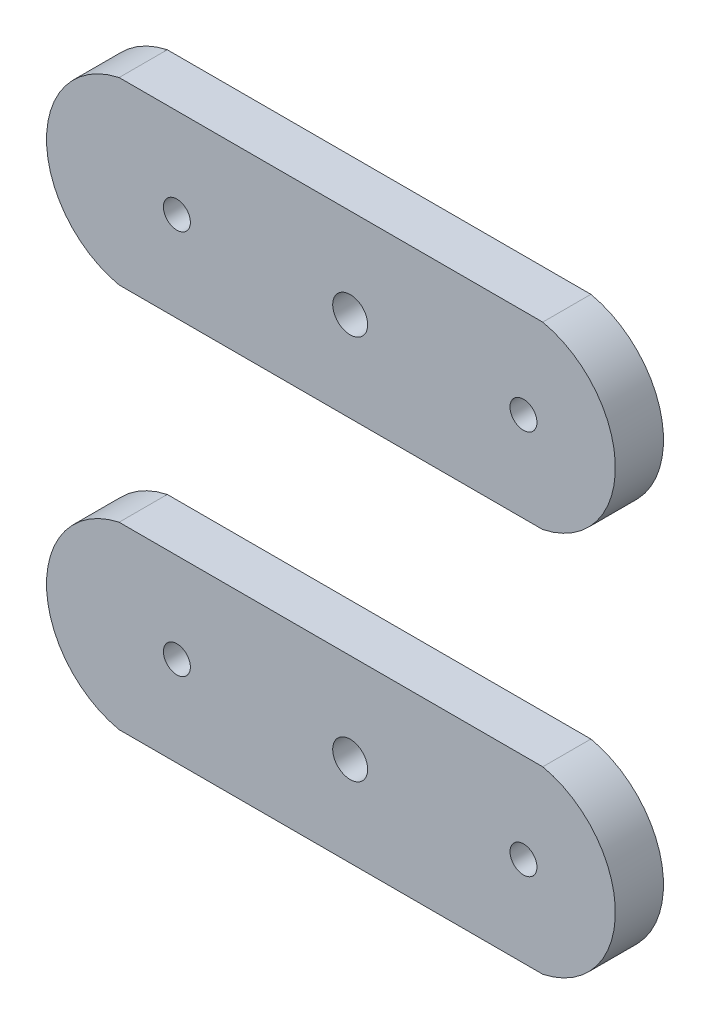
from build123d import *

# Parameters (mm, degrees)
SKETCH9_R           = 2.305
SKETCH9_R_2         = 1.778
BOSS_EXTRUDE1_DEPTH = 6.35


with BuildPart() as part:
    # Sketch9 → Boss-Extrude1 (new body)
    with BuildSketch(Plane.XY):
        with BuildLine():
            Line((19.05, 0), (69.85, 0))
            ThreePointArc((69.85, 0), (79.428440233, 11.849261314), (69.85, 23.698522628))
            Line((69.85, 23.698522628), (19.05, 23.698522628))
            Line((19.05, 23.698522628), (13.97, 23.698522628))
            ThreePointArc((13.97, 23.698522628), (4.391559767, 11.849261314), (13.97, 0))
            Line((13.97, 0), (19.05, 0))
        make_face()
        with Locations((44.45, 11.849261314)):
            Circle(SKETCH9_R, mode=Mode.SUBTRACT)
        with Locations((67.31, 11.849261314)):
            Circle(SKETCH9_R_2, mode=Mode.SUBTRACT)
        with Locations((21.59, 11.849261314)):
            Circle(SKETCH9_R_2, mode=Mode.SUBTRACT)
    extrude(amount=BOSS_EXTRUDE1_DEPTH)


with BuildPart() as body_2:
    # Body-Move/Copy1: copy of part
    add(part.part.moved(Location((0, 50.8, 0))))


solid = Compound([part.part, body_2.part])
